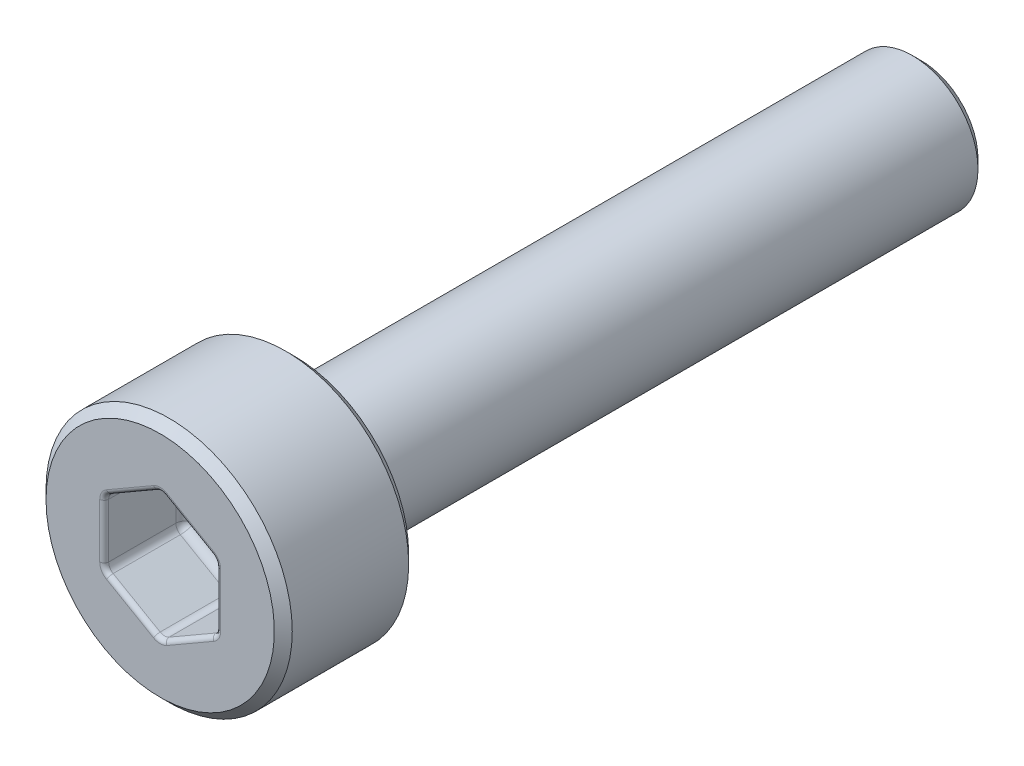
from build123d import *

# Parameters (mm, degrees)
SCHNITT_LINEAR_AUSTRAGEN1_DEPTH = 1.8
FASE1_SIZE                      = 0.2
VERRUNDUNG1_R                   = 0.2
VERRUNDUNG2_R                   = 0.1


with BuildPart() as part:
    # Skizze1 → Rotation1 (revolve)
    with BuildSketch(Plane(origin=(0, 0, 0), x_dir=(0, 0, -1), z_dir=(1, 0, 0))):
        Polygon((-3, 0), (-3, 2.75), (0, 2.75), (0, 1.465), (14, 1.465), (14, 0), align=None)
    revolve(axis=Axis((0, 0, 21.919879518), (0, 0, -1)))

    # Skizze2 → Schnitt-Linear austragen1 (cut)
    with BuildSketch(Plane.XY.offset(3)):
        Polygon((1.25, -0.721687836), (1.25, 0.721687836), (0, 1.443375673), (-1.25, 0.721687836), (-1.25, -0.721687836), (0, -1.443375673), align=None)
    extrude(amount=-SCHNITT_LINEAR_AUSTRAGEN1_DEPTH, mode=Mode.SUBTRACT)

    # Fase1
    fase1_edges = [part.edges().sort_by_distance(p)[0] for p in [
        (0, -1.465, -14),
        (0, -2.75, 0),
        (0, -2.75, 3),
    ]]
    chamfer(fase1_edges, length=FASE1_SIZE)

    # Verrundung1
    verrundung1_edges = [part.edges().sort_by_distance(p)[0] for p in [
        (0.625, -1.082531755, 1.2),
        (1.25, -0.721687836, 2.1),
        (-0.625, -1.082531755, 1.2),
        (0, -1.443375673, 2.1),
        (-1.25, 0, 1.2),
        (-1.25, -0.721687836, 2.1),
        (-0.625, 1.082531755, 1.2),
        (-1.25, 0.721687836, 2.1),
        (0.625, 1.082531755, 1.2),
        (0, 1.443375673, 2.1),
        (1.25, 0, 1.2),
        (1.25, 0.721687836, 2.1),
        (0, -1.465, 0),
    ]]
    fillet(verrundung1_edges, radius=VERRUNDUNG1_R)

    # Verrundung2
    verrundung2_edges = [part.edges().sort_by_distance(p)[0] for p in [
        (-0.625, -1.082531755, 3),
        (-1.25, 0, 3),
        (-0.625, 1.082531755, 3),
        (0.625, 1.082531755, 3),
        (1.25, 0, 3),
        (0.625, -1.082531755, 3),
        (-1.223205081, -0.706217783, 3),
        (0, -1.412435565, 3),
        (1.223205081, -0.706217783, 3),
        (1.223205081, 0.706217783, 3),
        (0, 1.412435565, 3),
        (-1.223205081, 0.706217783, 3),
    ]]
    fillet(verrundung2_edges, radius=VERRUNDUNG2_R)


solid = part.part
